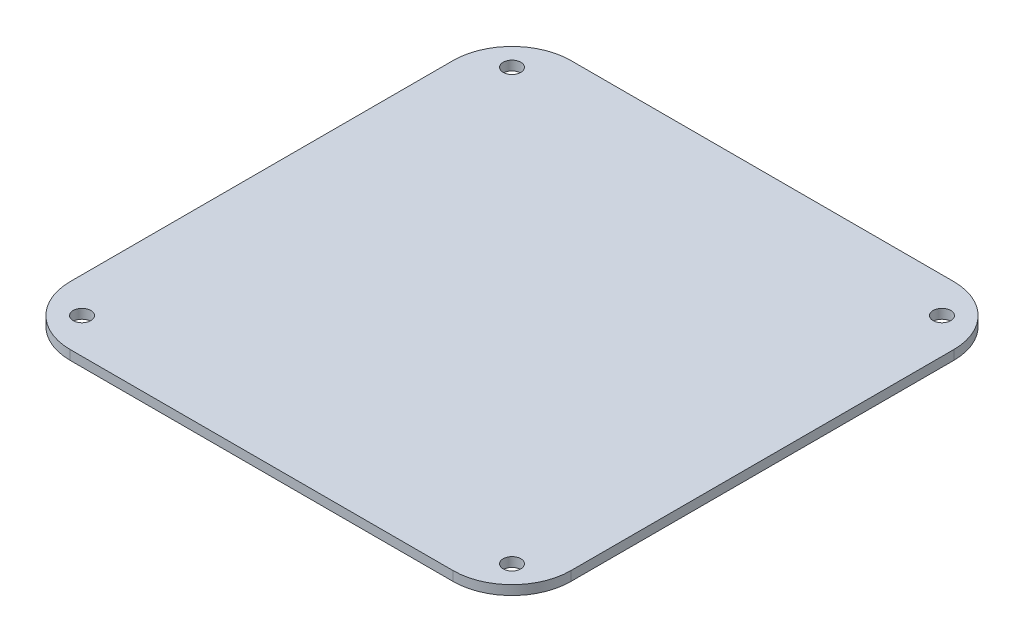
from build123d import *

# Parameters (mm, degrees)
SKETCH1_W           = 85
SKETCH1_H           = 85
SKETCH1_R           = 1.5
BOSS_EXTRUDE1_DEPTH = 1.6
FILLET1_R           = 10


with BuildPart() as part:
    # Sketch1 → Boss-Extrude1 (new body)
    with BuildSketch(Plane(origin=(0, 0, 0), x_dir=(1, 0, 0), z_dir=(0, 1, 0))):
        with Locations((42.5, 42.5)):
            Rectangle(SKETCH1_W, SKETCH1_H)
        with Locations((6, 79)):
            Circle(SKETCH1_R, mode=Mode.SUBTRACT)
        with Locations((6, 6)):
            Circle(SKETCH1_R, mode=Mode.SUBTRACT)
        with Locations((79, 6)):
            Circle(SKETCH1_R, mode=Mode.SUBTRACT)
        with Locations((79, 79)):
            Circle(SKETCH1_R, mode=Mode.SUBTRACT)
    extrude(amount=BOSS_EXTRUDE1_DEPTH)

    # Fillet1
    fillet1_edges = [part.edges().sort_by_distance(p)[0] for p in [
        (0, 0.8, -85),
        (85, 0.8, -85),
        (85, 0.8, 0),
        (0, 0.8, 0),
    ]]
    fillet(fillet1_edges, radius=FILLET1_R)


solid = part.part
